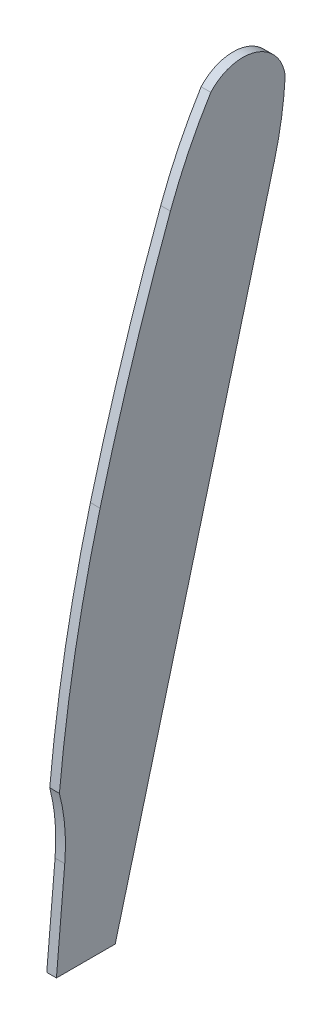
from build123d import *

# Parameters (mm, degrees)
BOSS_EXTRUDE1_DEPTH = 1.4


with BuildPart() as part:
    # Sketch5 → Boss-Extrude1 (new body)
    with BuildSketch(Plane(origin=(0, 0, 0), x_dir=(0, 0, -1), z_dir=(1, 0, 0))):
        with BuildLine():
            Line((8.5, 0), (31.496176528, 86.464518253))
            ThreePointArc((31.496176528, 86.464518253), (32.549833068, 91.44266763), (33.087424998, 96.502623979))
            ThreePointArc((33.087424998, 96.502623979), (28.738165872, 101.55), (22.321192242, 99.757094796))
            ThreePointArc((22.321192242, 99.757094796), (19.099282351, 93.925176434), (16.479305547, 87.799191071))
            ThreePointArc((16.479305547, 87.799191071), (11.015580961, 71.86120595), (6.309573463, 55.683284281))
            ThreePointArc((6.309573463, 55.683284281), (2.697084802, 39.416058531), (0.42798512, 22.907760782))
            ThreePointArc((0.42798512, 22.907760782), (1.208154251, 18.346362333), (1.20023358, 13.7187326))
            Line((1.20023358, 13.7187326), (0, 0))
            Line((0, 0), (8.5, 0))
        make_face()
    extrude(amount=BOSS_EXTRUDE1_DEPTH)


solid = part.part
